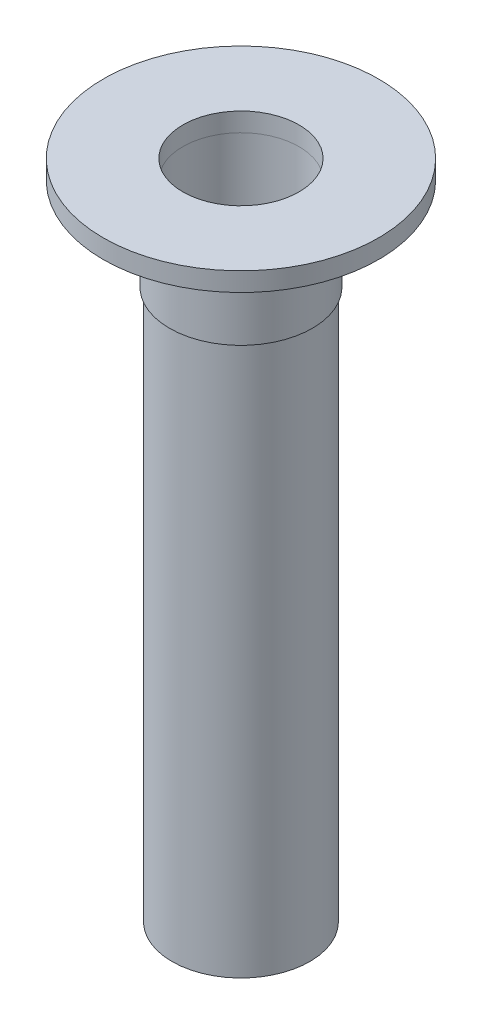
from build123d import *

# Parameters (mm, degrees)
SKETCH2_R          = 5.77
CUT_EXTRUDE1_DEPTH = 1.87
SKETCH3_R          = 5.785
CUT_EXTRUDE2_DEPTH = 9.2
SKETCH4_R          = 5.675
CUT_EXTRUDE3_DEPTH = 54.6


with BuildPart() as part:
    # Sketch1 → Revolve1 (revolve)
    with BuildSketch(Plane.XY):
        Polygon((0, 20.722884615), (0, -44.947115385), (-6.845, -44.947115385), (-6.845, 9.652884615), (-7.095, 9.652884615), (-7.095, 18.852884615), (-13.675, 18.852884615), (-13.675, 20.722884615), align=None)
    revolve(axis=Axis((0, 20.722884615, 0), (0, -1, 0)))

    # Sketch2 → Cut-Extrude1 (cut)
    with BuildSketch(Plane(origin=(0, 20.722884615, 0), x_dir=(1, 0, 0), z_dir=(0, 1, 0))):
        Circle(SKETCH2_R)
    extrude(amount=-CUT_EXTRUDE1_DEPTH, mode=Mode.SUBTRACT)

    # Sketch3 → Cut-Extrude2 (cut)
    with BuildSketch(Plane(origin=(0, 18.852884615, 0), x_dir=(1, 0, 0), z_dir=(0, 1, 0))):
        Circle(SKETCH3_R)
    extrude(amount=-CUT_EXTRUDE2_DEPTH, mode=Mode.SUBTRACT)

    # Sketch4 → Cut-Extrude3 (cut)
    with BuildSketch(Plane(origin=(0, 9.652884615, 0), x_dir=(1, 0, 0), z_dir=(0, 1, 0))):
        Circle(SKETCH4_R)
    extrude(amount=-CUT_EXTRUDE3_DEPTH, mode=Mode.SUBTRACT)


solid = part.part
